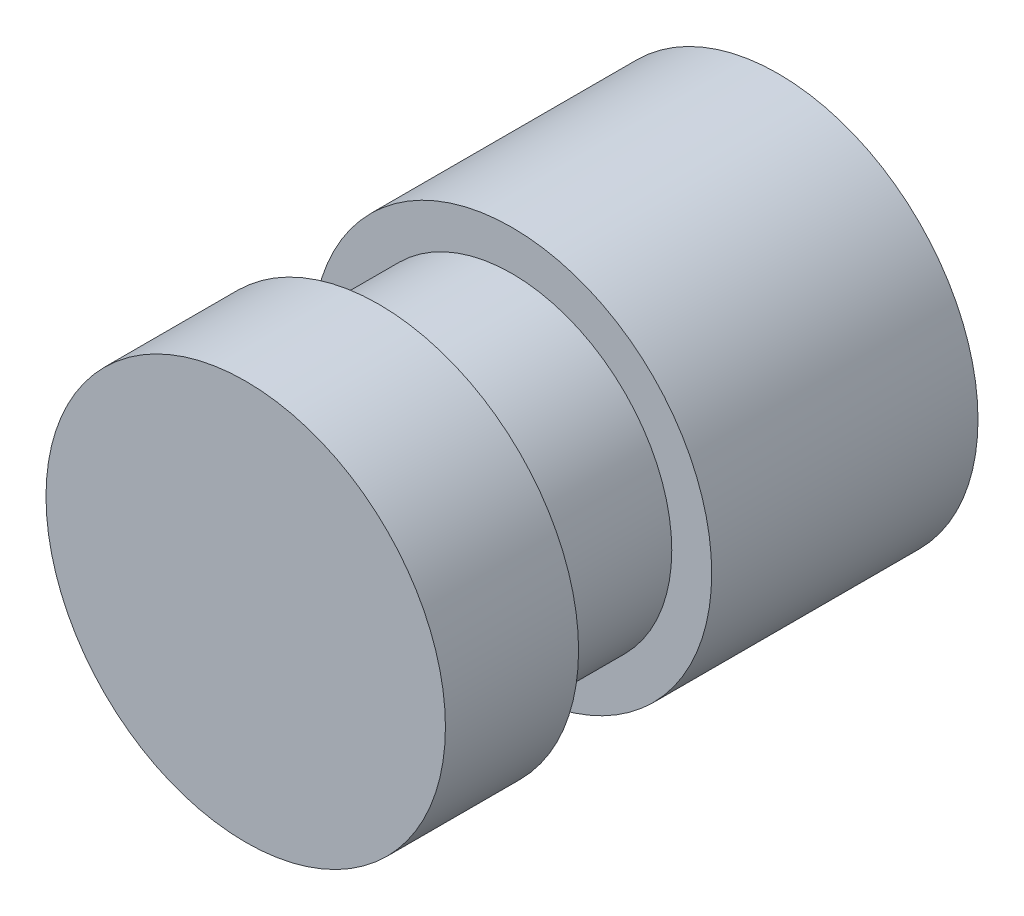
from build123d import *

# Parameters (mm, degrees)
SKETCH1_R               = 7.5
BOSS_EXTRUDE1_DEPTH     = 20
SKETCH4_R               = 7.5
SKETCH4_R_2             = 6
CUT_EXTRUDE2_DEPTH      = 2.5
CUT_EXTRUDE2_DEPTH_BACK = 2.5


with BuildPart() as part:
    # Sketch1 → Boss-Extrude1 (new body)
    with BuildSketch(Plane.XY):
        Circle(SKETCH1_R)
    extrude(amount=-BOSS_EXTRUDE1_DEPTH)

    # Sketch4 → Cut-Extrude2 (cut, two sides)
    with BuildSketch(Plane.XY.offset(-7.5)) as cut_extrude2_sk:
        Circle(SKETCH4_R)
        Circle(SKETCH4_R_2, mode=Mode.SUBTRACT)
    extrude(amount=CUT_EXTRUDE2_DEPTH, mode=Mode.SUBTRACT)
    extrude(cut_extrude2_sk.sketch, amount=-CUT_EXTRUDE2_DEPTH_BACK, mode=Mode.SUBTRACT)


solid = part.part
